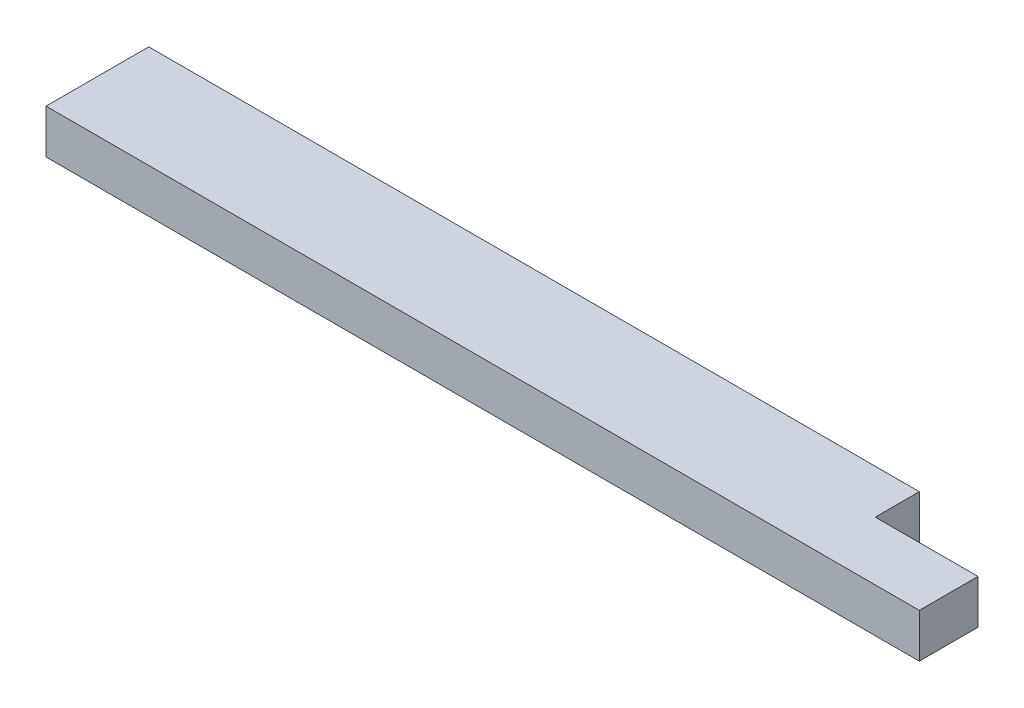
from build123d import *

# Parameters (mm, degrees)
SKETCH1_W           = 755.65
SKETCH1_H           = 88.9
BOSS_EXTRUDE1_DEPTH = 38.1
SKETCH2_W           = 88.9
SKETCH2_H           = 38.1
CUT_EXTRUDE1_DEPTH  = 39.1


with BuildPart() as part:
    # Sketch1 → Boss-Extrude1 (new body)
    with BuildSketch(Plane(origin=(0, 0, 0), x_dir=(1, 0, 0), z_dir=(0, 1, 0))):
        with Locations((377.825, 44.45)):
            Rectangle(SKETCH1_W, SKETCH1_H)
    extrude(amount=BOSS_EXTRUDE1_DEPTH)

    # Sketch2 → Cut-Extrude1 (cut, through all)
    with BuildSketch(Plane.XZ):
        with Locations((711.2, -69.85)):
            Rectangle(SKETCH2_W, SKETCH2_H)
    extrude(amount=-CUT_EXTRUDE1_DEPTH, mode=Mode.SUBTRACT)


solid = part.part
